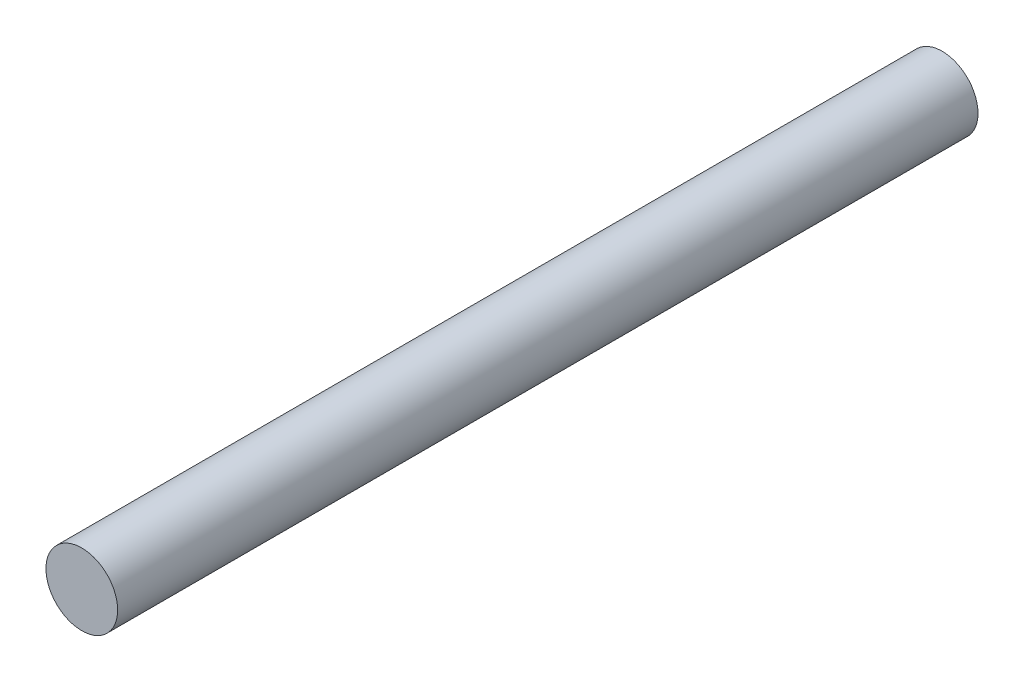
from build123d import *

# Parameters (mm, degrees)
SKETCH1_R           = 5
BOSS_EXTRUDE1_DEPTH = 120


with BuildPart() as part:
    # Sketch1 → Boss-Extrude1 (new body)
    with BuildSketch(Plane.XY):
        Circle(SKETCH1_R)
    extrude(amount=BOSS_EXTRUDE1_DEPTH)


solid = part.part
